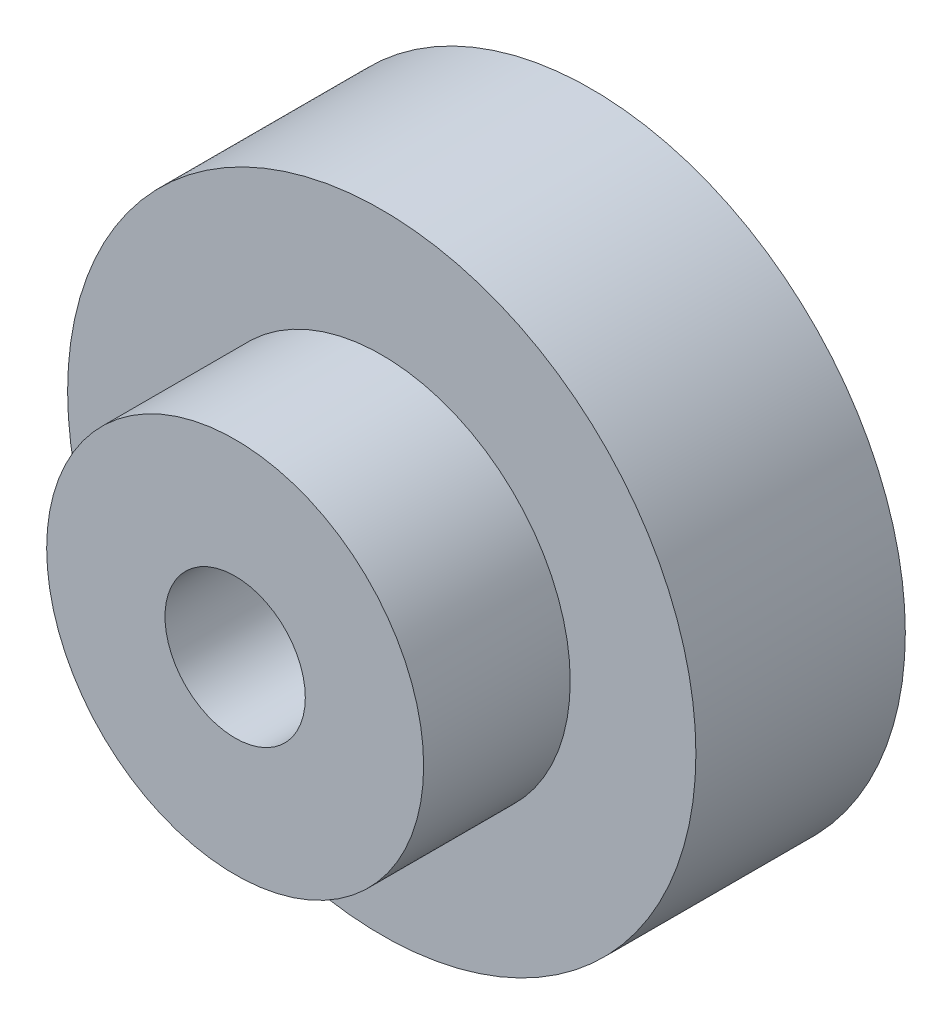
from build123d import *

# Parameters (mm, degrees)
ESBO_O1_R                = 15
ESBO_O1_R_2              = 3.35
RESSALTO_EXTRUS_O1_DEPTH = 10
ESBO_O2_R                = 9
ESBO_O2_R_2              = 3.35
RESSALTO_EXTRUS_O2_DEPTH = 7


with BuildPart() as part:
    # Esboço1 → Ressalto-extrusão1 (new body)
    with BuildSketch(Plane.XY):
        Circle(ESBO_O1_R)
        Circle(ESBO_O1_R_2, mode=Mode.SUBTRACT)
    extrude(amount=RESSALTO_EXTRUS_O1_DEPTH)

    # Esboço2 → Ressalto-extrusão2 (add)
    with BuildSketch(Plane.XY.offset(10)):
        Circle(ESBO_O2_R)
        Circle(ESBO_O2_R_2, mode=Mode.SUBTRACT)
    extrude(amount=RESSALTO_EXTRUS_O2_DEPTH)


solid = part.part
